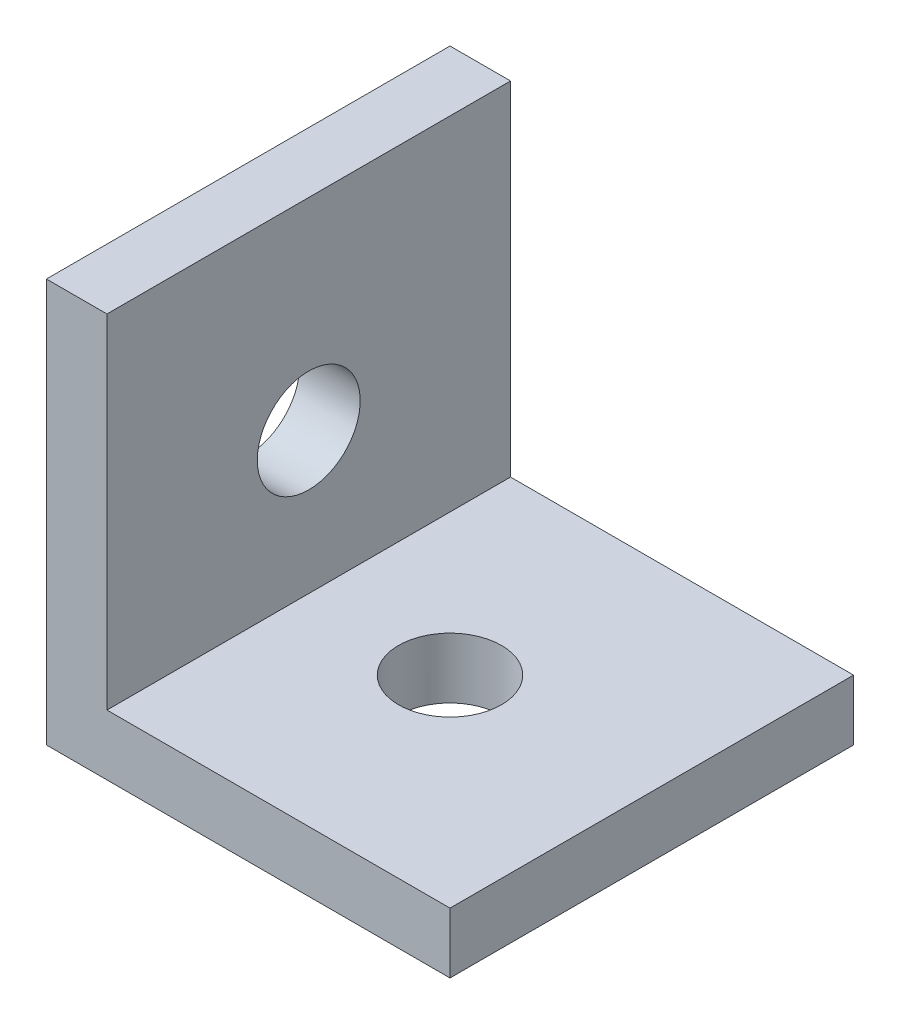
from build123d import *

# Parameters (mm, degrees)
BOSS_EXTRUDE1_DEPTH = 20
CUT_EXTRUDE1_REACH  = 22
SKETCH2_R           = 2.55
CUT_EXTRUDE2_REACH  = 22
SKETCH3_R           = 2.55


with BuildPart() as part:
    # Sketch1 → Boss-Extrude1 (new body)
    with BuildSketch(Plane.XY):
        Polygon((0, 20), (0, 0), (20, 0), (20, 3), (3, 3), (3, 20), align=None)
    extrude(amount=BOSS_EXTRUDE1_DEPTH)

    # Sketch2 → Cut-Extrude1 (cut, up to next)
    with BuildSketch(Plane.ZY, mode=Mode.PRIVATE) as cut_extrude1_sk1:
        with Locations((10, 10)):
            Circle(SKETCH2_R)
    cut_extrude1_tool1 = extrude(cut_extrude1_sk1.sketch, amount=-CUT_EXTRUDE1_REACH, mode=Mode.PRIVATE) & part.part
    add(cut_extrude1_tool1.solids().sort_by_distance((0, 10, 10))[0], mode=Mode.SUBTRACT)

    # Sketch3 → Cut-Extrude2 (cut, up to next)
    with BuildSketch(Plane.XZ, mode=Mode.PRIVATE) as cut_extrude2_sk1:
        with Locations((10, 10)):
            Circle(SKETCH3_R)
    cut_extrude2_tool1 = extrude(cut_extrude2_sk1.sketch, amount=-CUT_EXTRUDE2_REACH, mode=Mode.PRIVATE) & part.part
    add(cut_extrude2_tool1.solids().sort_by_distance((10, 0, 10))[0], mode=Mode.SUBTRACT)


solid = part.part
